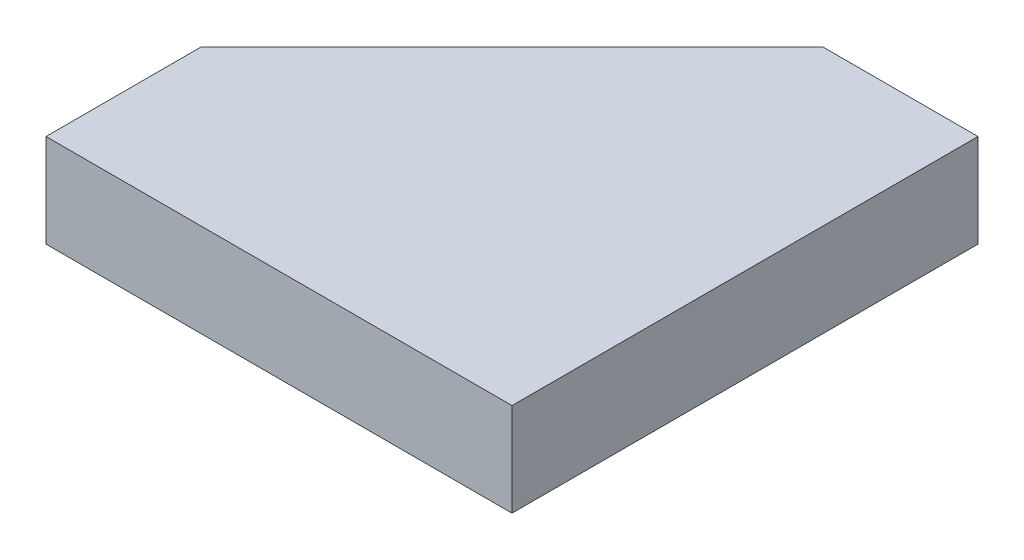
from build123d import *

# Parameters (mm, degrees)
SKETCH1_W           = 30
SKETCH1_H           = 30
BOSS_EXTRUDE1_DEPTH = 6
CHAMFER1_SIZE       = 20


with BuildPart() as part:
    # Sketch1 → Boss-Extrude1 (new body)
    with BuildSketch(Plane(origin=(0, 0, 0), x_dir=(1, 0, 0), z_dir=(0, 1, 0))):
        Rectangle(SKETCH1_W, SKETCH1_H)
    extrude(amount=BOSS_EXTRUDE1_DEPTH)

    # Chamfer1
    chamfer1_edges = [part.edges().sort_by_distance(p)[0] for p in [
        (-15, 3, -15),
    ]]
    chamfer(chamfer1_edges, length=CHAMFER1_SIZE)


solid = part.part
